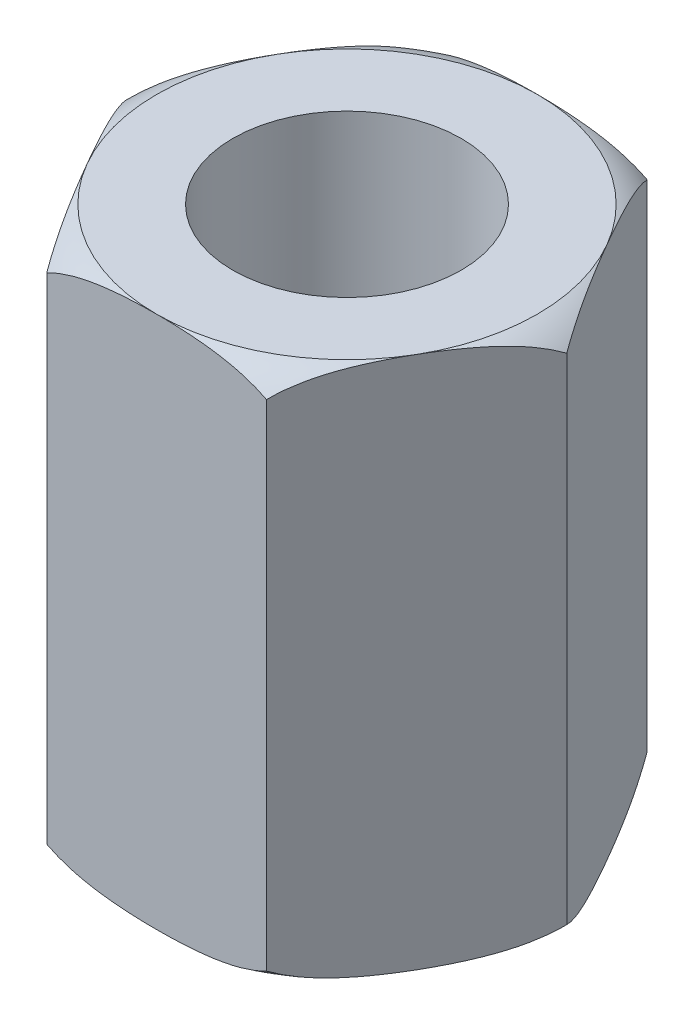
from build123d import *

# Parameters (mm, degrees)
SKETCH1_R           = 1.5
BOSS_EXTRUDE1_DEPTH = 7


with BuildPart() as part:
    # Sketch1 → Boss-Extrude1 (new body)
    with BuildSketch(Plane(origin=(0, 0, 0), x_dir=(1, 0, 0), z_dir=(0, 1, 0))):
        Polygon((2.886751346, 0), (1.443375673, 2.5), (-1.443375673, 2.5), (-2.886751346, 0), (-1.443375673, -2.5), (1.443375673, -2.5), align=None)
        Circle(SKETCH1_R, mode=Mode.SUBTRACT)
    extrude(amount=BOSS_EXTRUDE1_DEPTH)

    # Sketch5 → Cut-Revolve4 (revolve, cut)
    with BuildSketch(Plane.XY):
        with BuildLine():
            Line((-2.5, 0), (-2.886751346, 0))
            Line((-2.886751346, 0), (-2.886751346, 0.25))
            ThreePointArc((-2.886751346, 0.25), (-2.707962836, 0.102433581), (-2.5, 0))
        make_face()
        with BuildLine():
            Line((-2.886751346, 7), (-2.886751346, 6.75))
            ThreePointArc((-2.886751346, 6.75), (-2.707962836, 6.897566419), (-2.5, 7))
            Line((-2.5, 7), (-2.886751346, 7))
        make_face()
    revolve(axis=Axis((0, 7.426750378, 0), (0, -1, 0)), mode=Mode.SUBTRACT)


solid = part.part
